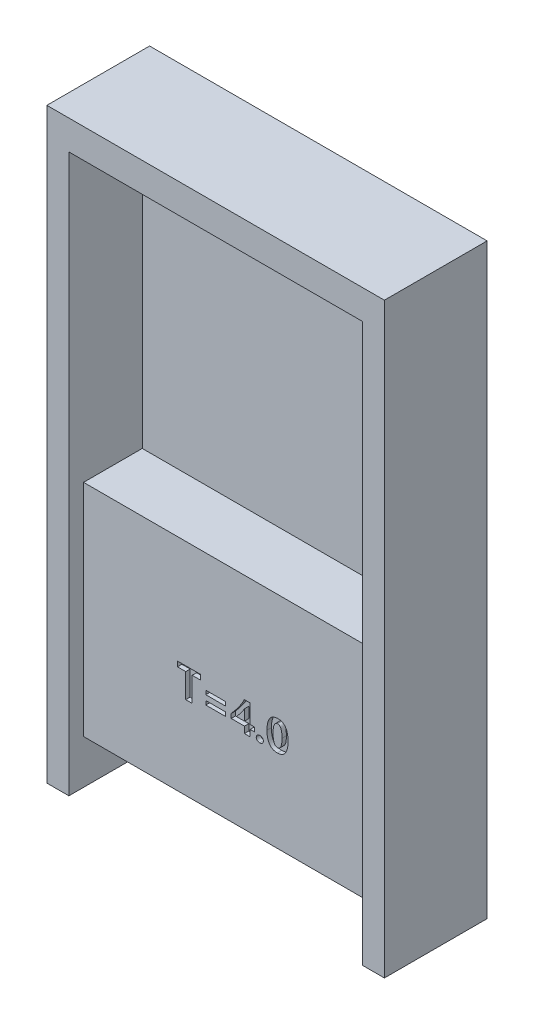
from build123d import *

# Parameters (mm, degrees)
EXTRUDE_1_DEPTH     = 7
SKETCH_2_W          = 20
SKETCH_2_H          = 35
EXTRUDE_2_DEPTH     = 6
SKETCH_3_W          = 20
SKETCH_3_H          = 20
CUT_EXTRUDE_1_DEPTH = 4
SKETCH_4_W          = 14
SKETCH_4_H          = 10
CUT_EXTRUDE_2_DEPTH = 5
SKETCH_5_W          = 1.341463414
SKETCH_5_H          = 0.268292683
CUT_EXTRUDE_3_DEPTH = 0.3


with BuildPart() as part:
    # 草图1 → 凸台-拉伸1 (new body)
    with BuildSketch(Plane.XY):
        Polygon((-10, 0), (-10, -18), (-11.5, -18), (-11.5, 22), (11.5, 22), (11.5, -18), (10, -18), (10, 0), (10, 20), (-10, 20), align=None)
    extrude(amount=EXTRUDE_1_DEPTH)

    # 草图2 → 凸台-拉伸2 (add)
    with BuildSketch(Plane.XY):
        with Locations((0, 2.5)):
            Rectangle(SKETCH_2_W, SKETCH_2_H)
    extrude(amount=EXTRUDE_2_DEPTH)

    # 草图3 → 切除-拉伸1 (cut)
    with BuildSketch(Plane.XY.offset(6)):
        with Locations((0, 10)):
            Rectangle(SKETCH_3_W, SKETCH_3_H)
    extrude(amount=-CUT_EXTRUDE_1_DEPTH, mode=Mode.SUBTRACT)

    # 草图4 → 切除-拉伸2 (cut)
    with BuildSketch(Plane(origin=(0, 0, 0), x_dir=(-1, 0, 0), z_dir=(0, 0, -1))):
        with Locations((0, -7)):
            Rectangle(SKETCH_4_W, SKETCH_4_H)
    extrude(amount=-CUT_EXTRUDE_2_DEPTH, mode=Mode.SUBTRACT)

    # 草图5 → 切除-拉伸3 (cut)
    with BuildSketch(Plane.XY.offset(6)):
        Polygon((-2.038957757, -7.685646489), (-2.599933366, -7.685646489), (-2.599933366, -9.344183074), (-3.038957757, -9.344183074), (-3.038957757, -7.685646489), (-3.599933366, -7.685646489), (-3.599933366, -7.344183074), (-2.038957757, -7.344183074), align=None)
        with Locations((-1.002372391, -8.234426976)):
            Rectangle(SKETCH_5_W, SKETCH_5_H)
        with Locations((-1.002372391, -8.844183075)):
            Rectangle(SKETCH_5_W, SKETCH_5_H)
        with BuildLine():
            Line((1.351286146, -7.344183074), (1.351286146, -8.612475757))
            Line((1.351286146, -8.612475757), (1.643969073, -8.612475757))
            Line((1.643969073, -8.612475757), (1.643969073, -8.905158684))
            Line((1.643969073, -8.905158684), (1.351286146, -8.905158684))
            Line((1.351286146, -8.905158684), (1.351286146, -9.344183074))
            Line((1.351286146, -9.344183074), (0.961042243, -9.344183074))
            Line((0.961042243, -9.344183074), (0.961042243, -8.905158684))
            Line((0.961042243, -8.905158684), (0.058603219, -8.905158684))
            Line((0.058603219, -8.905158684), (0.058603219, -8.609808074))
            add(Edge.make_bspline(
                [(0.058603219, -8.609808074), (0.104917563, -8.557754266), (0.197714473, -8.453457581), (0.331140338, -8.291687755), (0.460613802, -8.125888652), (0.563758226, -7.984499232), (0.643100029, -7.871397958), (0.698674774, -7.788760944), (0.750577629, -7.708554499), (0.799065638, -7.631123685), (0.843173548, -7.555813121), (0.884159992, -7.483446159), (0.921291943, -7.413362951), (0.943654353, -7.366866032), (0.954563585, -7.344183074)],
                knots=[0, 0, 0, 0, 0.00020901, 0.000418779, 0.000628952, 0.000840019, 0.000943734, 0.001043407, 0.001138755, 0.001230333, 0.001317458, 0.001400559, 0.001479828, 0.001555333, 0.001555333, 0.001555333, 0.001555333], degree=3))
            Line((0.954563585, -7.344183074), (1.351286146, -7.344183074))
        make_face()
        with BuildLine():
            Line((0.426743463, -8.612475757), (0.961042243, -8.612475757))
            Line((0.961042243, -8.612475757), (0.961042243, -7.881149538))
            add(Edge.make_bspline(
                [(0.961042243, -7.881149538), (0.949520566, -7.901573287), (0.925042452, -7.944964092), (0.882584109, -8.011800616), (0.83451151, -8.085513104), (0.788582345, -8.150259323), (0.747866448, -8.206622143), (0.71269205, -8.253322588), (0.674368973, -8.304110195), (0.631776286, -8.358259383), (0.585765511, -8.416419812), (0.536352317, -8.478620303), (0.482730401, -8.544208367), (0.445804396, -8.589233904), (0.426743463, -8.612475757)],
                knots=[0, 0, 0, 0, 7.0337e-05, 0.000149433, 0.00023748, 0.000334327, 0.000387535, 0.000446072, 0.000509716, 0.000578404, 0.000652742, 0.000732198, 0.000816716, 0.000906891, 0.000906891, 0.000906891, 0.000906891], degree=3))
        make_face(mode=Mode.SUBTRACT)
        with BuildLine():
            add(Edge.make_bspline(
                [(1.765920292, -9.148298928), (1.766728688, -9.13293706), (1.768306553, -9.10295307), (1.782811043, -9.060401528), (1.805672247, -9.022074277), (1.837676301, -8.989577343), (1.875610321, -8.963244909), (1.91772659, -8.943269281), (1.963730332, -8.93166491), (1.995531011, -8.93026298), (2.011728219, -8.929548928)],
                knots=[0, 0, 0, 0, 4.596e-05, 8.9706e-05, 0.0001333, 0.000178849, 0.000225368, 0.000271229, 0.000317999, 0.000366548, 0.000366548, 0.000366548, 0.000366548], degree=3))
            add(Edge.make_bspline(
                [(2.011728219, -8.929548928), (2.028065988, -8.930204709), (2.05992891, -8.931483653), (2.105735531, -8.943744006), (2.147528564, -8.963762738), (2.18423842, -8.991316277), (2.215381989, -9.023891566), (2.237566329, -9.062037881), (2.251651901, -9.103881831), (2.253026177, -9.133323908), (2.25372517, -9.148298928)],
                knots=[0, 0, 0, 0, 4.8929e-05, 9.5425e-05, 0.000141105, 0.000187143, 0.000232444, 0.00027532, 0.000318586, 0.000363371, 0.000363371, 0.000363371, 0.000363371], degree=3))
            add(Edge.make_bspline(
                [(2.25372517, -9.148298928), (2.253059897, -9.164038906), (2.251767619, -9.194613446), (2.237626519, -9.237827101), (2.215707139, -9.276743138), (2.184233619, -9.309179905), (2.147084973, -9.336108296), (2.104121523, -9.354752487), (2.056955565, -9.366632061), (2.023871778, -9.367911895), (2.006773951, -9.368573318)],
                knots=[0, 0, 0, 0, 4.7062e-05, 9.1417e-05, 0.000134952, 0.000179975, 0.000225872, 0.000271763, 0.000319642, 0.000370851, 0.000370851, 0.000370851, 0.000370851], degree=3))
            add(Edge.make_bspline(
                [(2.006773951, -9.368573318), (1.990685107, -9.367928817), (1.959312571, -9.366672068), (1.914249958, -9.354238924), (1.872689627, -9.334587328), (1.835651356, -9.307320667), (1.804757726, -9.274061435), (1.781858097, -9.235889571), (1.768574281, -9.193232366), (1.766818533, -9.163506622), (1.765920292, -9.148298928)],
                knots=[0, 0, 0, 0, 4.8169e-05, 9.3928e-05, 0.0001391, 0.000185444, 0.000231025, 0.000274423, 0.000317937, 0.000363517, 0.000363517, 0.000363517, 0.000363517], degree=3))
        make_face()
        with BuildLine():
            add(Edge.make_bspline(
                [(2.497627609, -8.376195269), (2.498230233, -8.33464218), (2.499401877, -8.253853166), (2.507935403, -8.136474627), (2.523257169, -8.026666137), (2.543957517, -7.924494932), (2.570431815, -7.82963793), (2.603539961, -7.742666222), (2.642506018, -7.663044715), (2.687420852, -7.591114942), (2.738230473, -7.527107963), (2.794453931, -7.471292359), (2.856427318, -7.424387451), (2.923674341, -7.385964838), (2.996325018, -7.356118715), (3.074234537, -7.334776161), (3.157523848, -7.32205823), (3.214807974, -7.320560992), (3.244197731, -7.31979283)],
                knots=[0, 0, 0, 0, 0.000124656, 0.000242361, 0.000352793, 0.000457056, 0.000554894, 0.000647895, 0.00073584, 0.00082043, 0.00090179, 0.000980479, 0.001057462, 0.001134275, 0.001212195, 0.001292447, 0.001376096, 0.001464229, 0.001464229, 0.001464229, 0.001464229], degree=3))
            add(Edge.make_bspline(
                [(3.244197731, -7.31979283), (3.272188336, -7.320454731), (3.326656093, -7.321742742), (3.40556172, -7.333729971), (3.479155402, -7.353532371), (3.547305111, -7.381394564), (3.610203574, -7.417109594), (3.66731398, -7.461027231), (3.719369716, -7.512602014), (3.765440046, -7.572474148), (3.806041453, -7.640202958), (3.840792411, -7.715765572), (3.871231096, -7.79870889), (3.89465707, -7.889985846), (3.913746585, -7.988857083), (3.927247967, -8.095650511), (3.93522796, -8.210294457), (3.936167079, -8.289291677), (3.936651999, -8.330082464)],
                knots=[0, 0, 0, 0, 8.3928e-05, 0.000163318, 0.000238757, 0.000312076, 0.000383594, 0.000455091, 0.000527581, 0.00060282, 0.000681118, 0.000763978, 0.000851986, 0.000945811, 0.001046338, 0.001153923, 0.001268532, 0.001390894, 0.001390894, 0.001390894, 0.001390894], degree=3))
            add(Edge.make_bspline(
                [(3.936651999, -8.330082464), (3.936078467, -8.370369234), (3.934964346, -8.448628653), (3.926028121, -8.562499037), (3.911921795, -8.669355116), (3.891418027, -8.769247732), (3.86484227, -8.862031598), (3.832528954, -8.94779122), (3.794366517, -9.026531177), (3.750285056, -9.097881664), (3.700560757, -9.161660234), (3.645584346, -9.217253621), (3.585208639, -9.264531097), (3.518975101, -9.302204726), (3.448027235, -9.332214433), (3.37176209, -9.353641392), (3.290226755, -9.366282859), (3.234080484, -9.367797573), (3.20532578, -9.368573318)],
                knots=[0, 0, 0, 0, 0.000120846, 0.000234751, 0.000342437, 0.00044401, 0.000540382, 0.000631688, 0.000718612, 0.000802475, 0.000882828, 0.000960707, 0.001036481, 0.001112112, 0.001188625, 0.001267042, 0.001349185, 0.001435415, 0.001435415, 0.001435415, 0.001435415], degree=3))
            add(Edge.make_bspline(
                [(3.20532578, -9.368573318), (3.176697592, -9.367928702), (3.121086839, -9.366676523), (3.040492389, -9.354482679), (2.96536629, -9.335312264), (2.895724029, -9.308057618), (2.831433459, -9.273186689), (2.772769474, -9.230324846), (2.720045831, -9.179150151), (2.672642567, -9.12059726), (2.631000854, -9.054116075), (2.595194597, -8.979897861), (2.564766207, -8.898106694), (2.540293114, -8.808510441), (2.520805095, -8.711369853), (2.507553962, -8.606420119), (2.498913399, -8.493845677), (2.49806512, -8.416227709), (2.497627609, -8.376195269)],
                knots=[0, 0, 0, 0, 8.5832e-05, 0.000166729, 0.000243912, 0.000318008, 0.000390486, 0.000462747, 0.000535249, 0.000610302, 0.000688227, 0.000770039, 0.000857106, 0.000949659, 0.00104839, 0.001154086, 0.001266822, 0.001386897, 0.001386897, 0.001386897, 0.001386897], degree=3))
        make_face()
        with BuildLine():
            add(Edge.make_bspline(
                [(2.912261755, -8.365905635), (2.912417692, -8.39360479), (2.912719713, -8.447252922), (2.916828949, -8.524889783), (2.922221966, -8.597260998), (2.930469688, -8.664315304), (2.941590032, -8.72595059), (2.954360971, -8.782418994), (2.969672169, -8.833521131), (2.988282903, -8.879062592), (3.008004884, -8.919818674), (3.031082191, -8.954799948), (3.056430751, -8.984647806), (3.084237425, -9.009331136), (3.114831663, -9.028304927), (3.147659342, -9.041768667), (3.182938181, -9.050088808), (3.207311765, -9.051021817), (3.219807487, -9.051500147)],
                knots=[0, 0, 0, 0, 8.3087e-05, 0.000160924, 0.000233178, 0.000300773, 0.000363493, 0.000420993, 0.000474397, 0.000523298, 0.000568462, 0.000610002, 0.000648651, 0.000685649, 0.000721077, 0.000756109, 0.0007917, 0.000829143, 0.000829143, 0.000829143, 0.000829143], degree=3))
            add(Edge.make_bspline(
                [(3.219807487, -9.051500147), (3.232054803, -9.051044613), (3.256090741, -9.050150606), (3.290746144, -9.041417208), (3.32310727, -9.027469832), (3.352966, -9.007822508), (3.380401064, -8.982536814), (3.405129028, -8.951677157), (3.427585898, -8.915533097), (3.447871619, -8.874087397), (3.465211652, -8.826879658), (3.480140971, -8.774183385), (3.493766246, -8.716290847), (3.503540338, -8.652654854), (3.512036095, -8.58366258), (3.518050044, -8.509034943), (3.521389094, -8.428945287), (3.521803864, -8.37378486), (3.522017853, -8.345326367)],
                knots=[0, 0, 0, 0, 3.6682e-05, 7.1991e-05, 0.000106469, 0.000141985, 0.00017867, 0.000217952, 0.000260247, 0.000306095, 0.000356141, 0.000410897, 0.000470339, 0.000534433, 0.000603919, 0.000678863, 0.000758967, 0.00084434, 0.00084434, 0.00084434, 0.00084434], degree=3))
            add(Edge.make_bspline(
                [(3.522017853, -8.345326367), (3.521812706, -8.316740336), (3.52141502, -8.261324969), (3.517960563, -8.180998139), (3.512387699, -8.106242247), (3.504397954, -8.037079025), (3.494394144, -7.97327604), (3.481339759, -7.915074789), (3.466762486, -7.862246785), (3.44958859, -7.815078633), (3.430305151, -7.773171344), (3.408384616, -7.736902467), (3.383975207, -7.706238424), (3.357713411, -7.680546194), (3.32844861, -7.660936371), (3.296870538, -7.646946085), (3.263083127, -7.638248179), (3.239676413, -7.637330973), (3.227810536, -7.636866001)],
                knots=[0, 0, 0, 0, 8.5755e-05, 0.000166239, 0.000241153, 0.000310594, 0.000375064, 0.000434794, 0.000489445, 0.000539359, 0.000585221, 0.000627639, 0.000666147, 0.000702535, 0.000737416, 0.000771196, 0.000805765, 0.000841307, 0.000841307, 0.000841307, 0.000841307], degree=3))
            add(Edge.make_bspline(
                [(3.227810536, -7.636866001), (3.215048074, -7.63728457), (3.189965152, -7.638107212), (3.153861293, -7.647395754), (3.119906889, -7.661471852), (3.088936845, -7.682219799), (3.060000918, -7.707953809), (3.033999343, -7.739686369), (3.010795822, -7.777108501), (2.989918812, -7.820071396), (2.971285676, -7.868633588), (2.955410165, -7.92295479), (2.942276735, -7.982972938), (2.931339585, -8.048613852), (2.922545915, -8.119933845), (2.916757897, -8.196876374), (2.912735513, -8.279480713), (2.91242334, -8.336428731), (2.912261755, -8.365905635)],
                knots=[0, 0, 0, 0, 3.8203e-05, 7.5083e-05, 0.000111112, 0.000148002, 0.000186328, 0.000226926, 0.000270594, 0.000318146, 0.000370023, 0.000426456, 0.000487757, 0.000554231, 0.000626033, 0.000703256, 0.000785661, 0.000874083, 0.000874083, 0.000874083, 0.000874083], degree=3))
        make_face(mode=Mode.SUBTRACT)
    extrude(amount=-CUT_EXTRUDE_3_DEPTH, mode=Mode.SUBTRACT)


solid = part.part
